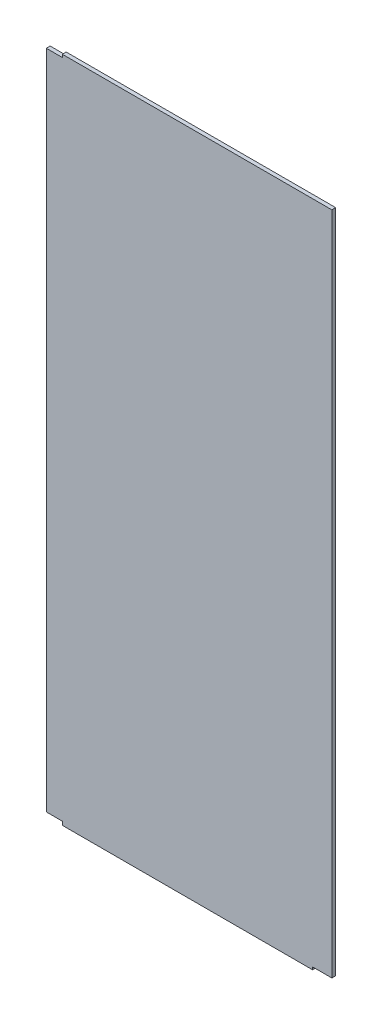
from build123d import *

# Parameters (mm, degrees)
SALIENTE_EXTRUIR1_DEPTH = 3


with BuildPart() as part:
    # Croquis1 → Saliente-Extruir1 (new body)
    with BuildSketch(Plane.XY):
        Polygon((-224.443201015, 296.131578947), (-14.243201015, 296.131578947), (-14.243201015, -222.668421053), (-29.243201015, -222.668421053), (-29.243201015, -224.668421053), (-224.443201015, -224.668421053), (-224.443201015, -221.868421053), (-236.943201015, -221.868421053), (-236.943201015, 293.931578947), (-224.443201015, 293.931578947), align=None)
    extrude(amount=SALIENTE_EXTRUIR1_DEPTH)


solid = part.part
